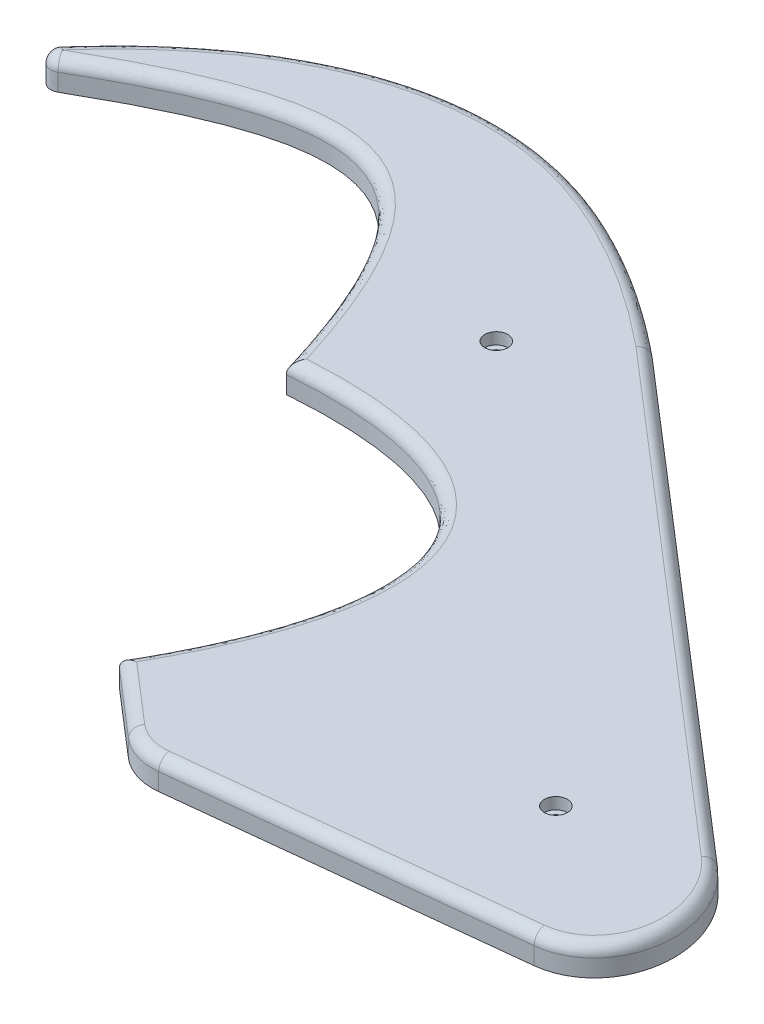
from build123d import *

# Parameters (mm, degrees)
BOSS_EXTRUDE1_DEPTH = 5
FILLET1_R           = 2
CUT_EXTRUDE1_REACH  = 7
SKETCH3_R           = 1
SKETCH4_R           = 2
CUT_EXTRUDE2_DEPTH  = 2


with BuildPart() as part:
    # Sketch1 → Boss-Extrude1 (new body)
    with BuildSketch(Plane(origin=(0, 10, 0), x_dir=(1, 0, 0), z_dir=(0, 1, 0))):
        with BuildLine():
            Line((682.311004276, -403.859625269), (741.003284698, -397.450090421))
            add(Edge.make_bspline(
                [(741.003284698, -397.450090421), (743.229040772, -397.207025046), (745.172628594, -396.200602066), (747.121620135, -395.191380948), (748.593081421, -393.513998219), (750.017625371, -391.890098602), (750.857748535, -389.792663012), (751.656716458, -387.797974815), (751.855622993, -385.547226857), (752.045396448, -383.399825241), (751.672102731, -381.189047369), (751.311045302, -379.050737137), (750.448541052, -377.011024532), (749.596433176, -374.995898028), (748.314628038, -373.220809333), (747.012727574, -371.417891927), (745.362011302, -369.994656598)],
                knots=[0, 0, 0, 0.125, 0.125, 0.25, 0.25, 0.375, 0.375, 0.5, 0.5, 0.625, 0.625, 0.75, 0.75, 0.875, 0.875, 1, 1, 1], degree=2))
            Line((745.362011302, -369.994656598), (663.109018972, -299.076736555))
            add(Edge.make_bspline(
                [(566.038084725, -304.477973393), (586.54103201, -281.390758171), (621.817594979, -269.935285183), (655.185758459, -292.56398835), (663.109018972, -299.076736555)],
                knots=[0.005774044, 0.005774044, 0.005774044, 0.005774044, 0.670804944, 1, 1, 1, 1], degree=3))
            ThreePointArc((566.038084725, -304.477973393), (565.982427594, -307.068600409), (568.53044365, -307.539833082))
            add(Edge.make_bspline(
                [(633.724319121, -333.15810118), (620.390742427, -289.57385369), (605.302826909, -286.396096636), (568.53044365, -307.539833082)],
                knots=[0, 0, 0, 0, 0.916017128, 0.916017128, 0.916017128, 0.916017128], degree=3))
            add(Edge.make_bspline(
                [(633.724319121, -333.15810118), (675.570533141, -329.918107769), (685.559855815, -353.389776531), (663.335012753, -391.697463282)],
                knots=[0, 0, 0, 0, 1, 1, 1, 1], degree=3))
            Line((663.335012753, -391.697463282), (674.695467628, -401.492363232))
            ThreePointArc((674.695467628, -401.492363232), (678.257040346, -403.468011201), (682.311004276, -403.859625269))
        make_face()
    extrude(amount=BOSS_EXTRUDE1_DEPTH)

    # Fillet1
    fillet1_edges = [part.edges().sort_by_distance(p)[0] for p in [
        (610.552914119, 15, 296.316493128),
        (565.982427594, 15, 307.068600409),
        (610.552914119, 15, 296.316493128),
        (704.235515137, 15, 334.535696576),
        (751.854411192, 15, 385.560874329),
        (711.657144487, 15, 400.654857845),
        (678.257040346, 15, 403.468011201),
        (669.01524019, 15, 396.594913257),
        (673.295664736, 15, 348.573252658),
    ]]
    fillet(fillet1_edges, radius=FILLET1_R)

    # Sketch3 → Cut-Extrude1 (cut, up to next)
    with BuildSketch(Plane.XZ.offset(-10), mode=Mode.PRIVATE) as cut_extrude1_sk1:
        with Locations((648.909548112, 311.921081714)):
            Circle(SKETCH3_R)
    cut_extrude1_tool1 = extrude(cut_extrude1_sk1.sketch, amount=-CUT_EXTRUDE1_REACH, mode=Mode.PRIVATE) & part.part
    add(cut_extrude1_tool1.solids().sort_by_distance((648.909548, 10, 311.921082))[0], mode=Mode.SUBTRACT)
    # Sketch3 → Cut-Extrude1 (cut, up to next)
    with BuildSketch(Plane.XZ.offset(-10), mode=Mode.PRIVATE) as cut_extrude1_sk2:
        with Locations((723.888550287, 376.567421385)):
            Circle(SKETCH3_R)
    cut_extrude1_tool2 = extrude(cut_extrude1_sk2.sketch, amount=-CUT_EXTRUDE1_REACH, mode=Mode.PRIVATE) & part.part
    add(cut_extrude1_tool2.solids().sort_by_distance((723.88855, 10, 376.567421))[0], mode=Mode.SUBTRACT)

    # Sketch4 → Cut-Extrude2 (cut)
    with BuildSketch(Plane(origin=(0, 15, 0), x_dir=(1, 0, 0), z_dir=(0, 1, 0))):
        with Locations((648.909548112, -311.921081714)):
            Circle(SKETCH4_R)
        with Locations((723.888550287, -376.567421385)):
            Circle(SKETCH4_R)
    extrude(amount=-CUT_EXTRUDE2_DEPTH, mode=Mode.SUBTRACT)


solid = part.part
